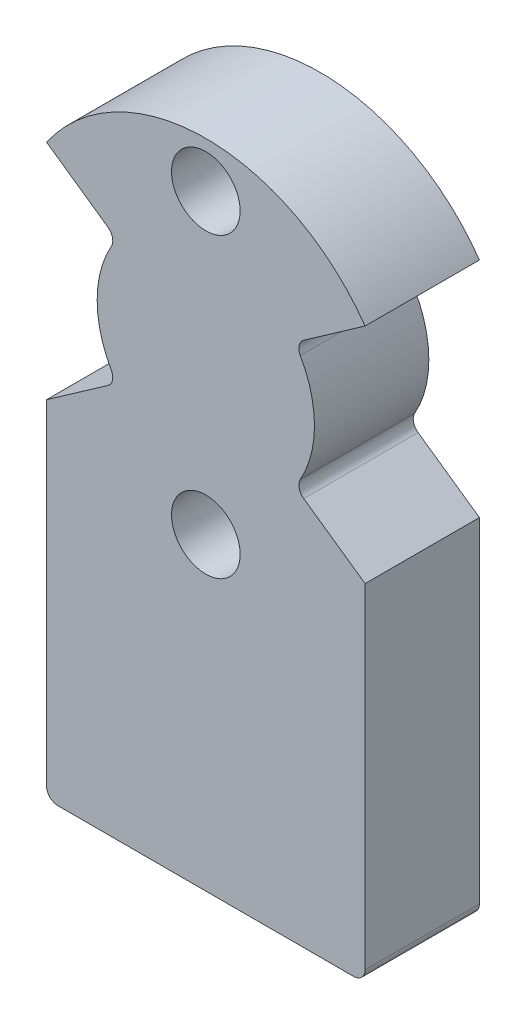
from build123d import *

# Parameters (mm, degrees)
SKETCH_1_R          = 8.5
EXTRUDE_1_DEPTH     = 5
SKETCH_2_R          = 1.5
CUT_EXTRUDE_1_DEPTH = 5
CUT_EXTRUDE_2_DEPTH = 6
EXTRUDE_2_DEPTH     = 5
FILLET_1_R          = 0.5
FILLET_2_R          = 0.5


with BuildPart() as part:
    # 草图1 → 凸台-拉伸1 (new body)
    with BuildSketch(Plane.XY):
        Circle(SKETCH_1_R)
    extrude(amount=EXTRUDE_1_DEPTH)

    # 草图2 → 切除-拉伸1 (cut)
    with BuildSketch(Plane.XY.offset(5)):
        with Locations((0, 6.5)):
            Circle(SKETCH_2_R)
        with Locations((0, -6.5)):
            Circle(SKETCH_2_R)
    extrude(amount=-CUT_EXTRUDE_1_DEPTH, mode=Mode.SUBTRACT)

    # 草图3 → 切除-拉伸2 (cut, through all)
    with BuildSketch(Plane(origin=(0, 0, 0), x_dir=(-1, 0, 0), z_dir=(0, 0, -1))):
        with BuildLine():
            Line((6.962792376, 4.875399709), (3.89097221, 2.724488073))
            ThreePointArc((3.89097221, 2.724488073), (4.530155516, 1.428352548), (4.75, 0))
            ThreePointArc((4.75, 0), (4.530155516, -1.428352548), (3.89097221, -2.724488073))
            Line((3.89097221, -2.724488073), (6.962792376, -4.875399709))
            ThreePointArc((6.962792376, -4.875399709), (8.106594081, -2.555999296), (8.5, 0))
            ThreePointArc((8.5, 0), (8.106594081, 2.555999296), (6.962792376, 4.875399709))
        make_face()
    cut_extrude_2 = extrude(amount=-CUT_EXTRUDE_2_DEPTH, mode=Mode.SUBTRACT)

    # 镜向1: 切除-拉伸2 across plane
    add(cut_extrude_2.mirror(Plane(origin=(0, 0, 0), x_dir=(0, 0, 1), z_dir=(1, 0, 0))), mode=Mode.SUBTRACT)


with BuildPart() as body_2:
    # 草图4 → 凸台-拉伸2 (new body)
    with BuildSketch(Plane(origin=(0, 0, 0), x_dir=(-1, 0, 0), z_dir=(0, 0, -1))):
        with BuildLine():
            ThreePointArc((6.962792376, -4.875399709), (0, -8.5), (-6.962792376, -4.875399709))
            Line((-6.962792376, -4.875399709), (-6.962792376, -20))
            Line((-6.962792376, -20), (6.962792376, -20))
            Line((6.962792376, -20), (6.962792376, -4.875399709))
        make_face()
    extrude(amount=-EXTRUDE_2_DEPTH)


with BuildPart() as part_1:
    add(part.part)

    # Combine 1: union body 2
    add(body_2.part)

    # 圆角1
    fillet_1_edges = [part_1.edges().sort_by_distance(p)[0] for p in [
        (-3.89097221, -2.724488073, 2.5),
        (-3.89097221, 2.724488073, 2.5),
        (3.89097221, 2.724488073, 2.5),
        (3.89097221, -2.724488073, 2.5),
    ]]
    fillet(fillet_1_edges, radius=FILLET_1_R)

    # 圆角2
    fillet_2_edges = [part_1.edges().sort_by_distance(p)[0] for p in [
        (-6.962792376, -20, 2.5),
        (6.962792376, -20, 2.5),
    ]]
    fillet(fillet_2_edges, radius=FILLET_2_R)


solid = part_1.part
